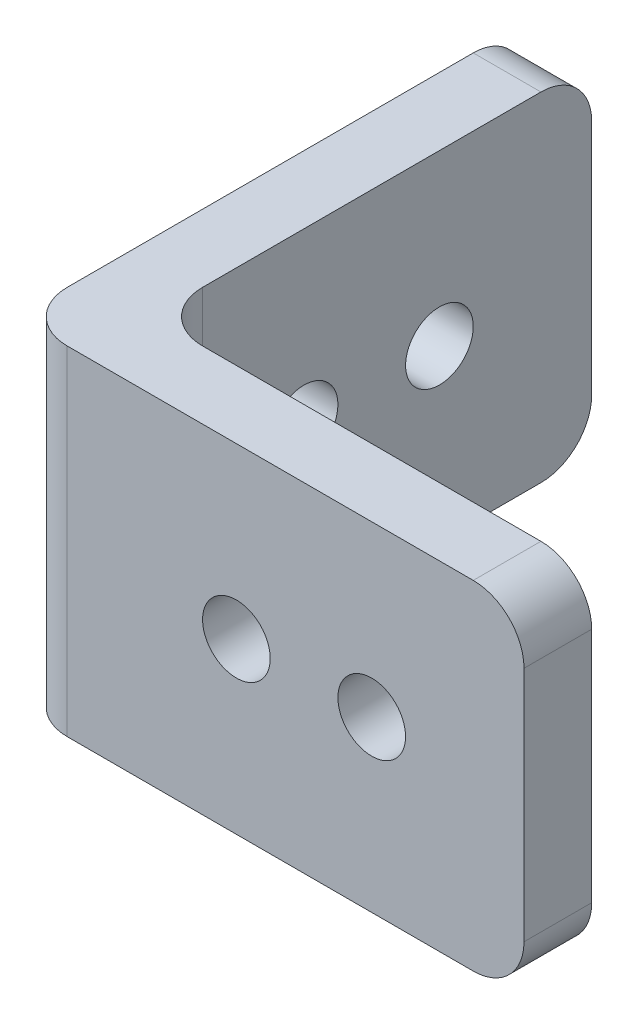
from build123d import *

# Parameters (mm, degrees)
BOSS_EXTRUDE1_DEPTH = 20
SKETCH2_R           = 2
CUT_EXTRUDE1_DEPTH  = 5
SKETCH3_R           = 2
CUT_EXTRUDE2_DEPTH  = 5
FILLET1_R           = 3


with BuildPart() as part:
    # Sketch1 → Boss-Extrude1 (new body)
    with BuildSketch(Plane(origin=(0, 0, 0), x_dir=(1, 0, 0), z_dir=(0, 1, 0))):
        Polygon((0, 0), (0, 30), (4, 30), (4, 4), (30, 4), (30, 0), align=None)
    extrude(amount=BOSS_EXTRUDE1_DEPTH)

    # Sketch2 → Cut-Extrude1 (cut, through all)
    with BuildSketch(Plane(origin=(4, 0, 0), x_dir=(0, 0, -1), z_dir=(1, 0, 0))):
        with Locations((13, 10)):
            Circle(SKETCH2_R)
        with Locations((21, 10)):
            Circle(SKETCH2_R)
    extrude(amount=-CUT_EXTRUDE1_DEPTH, mode=Mode.SUBTRACT)

    # Sketch3 → Cut-Extrude2 (cut, through all)
    with BuildSketch(Plane(origin=(0, 0, -4), x_dir=(-1, 0, 0), z_dir=(0, 0, -1))):
        with Locations((-21, 10)):
            Circle(SKETCH3_R)
        with Locations((-13, 10)):
            Circle(SKETCH3_R)
    extrude(amount=-CUT_EXTRUDE2_DEPTH, mode=Mode.SUBTRACT)

    # Fillet1
    fillet1_edges = [part.edges().sort_by_distance(p)[0] for p in [
        (0, 10, 0),
        (4, 10, -4),
        (2, 20, -30),
        (2, 0, -30),
        (30, 20, -2),
        (30, 0, -2),
    ]]
    fillet(fillet1_edges, radius=FILLET1_R)


solid = part.part
